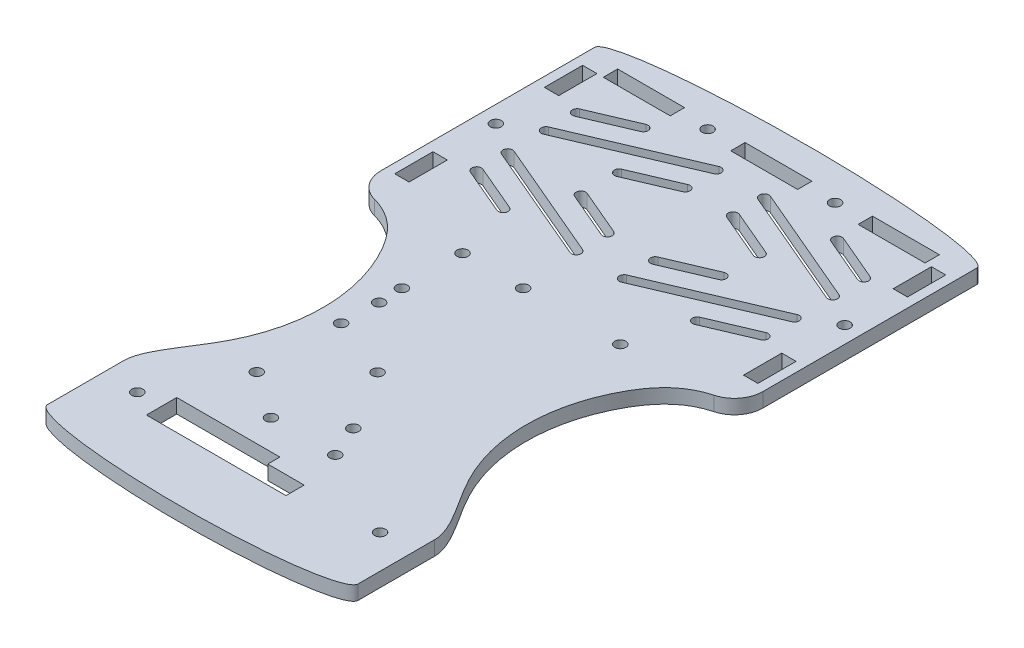
from build123d import *

# Parameters (mm, degrees)
SKETCH1_W           = 80
SKETCH1_H           = 100
BOSS_EXTRUDE1_DEPTH = 1.5
SKETCH2_R           = 1.15
SKETCH2_W           = 14
SKETCH2_H           = 3
CUT_EXTRUDE1_DEPTH  = 4
SKETCH3_R           = 1.15
SKETCH3_W           = 3
SKETCH3_H           = 8
CUT_EXTRUDE2_DEPTH  = 4
CUT_EXTRUDE3_DEPTH  = 4
BOSS_EXTRUDE2_DEPTH = 3
SKETCH9_W           = 80
SKETCH9_H           = 6
BOSS_EXTRUDE3_DEPTH = 3
CUT_EXTRUDE4_DEPTH  = 4.0000001
BOSS_EXTRUDE4_DEPTH = 3
SKETCH12_R          = 1.143
CUT_EXTRUDE5_DEPTH  = 4.0000001
SKETCH13_R          = 1.15
CUT_EXTRUDE6_DEPTH  = 4.0000001
CUT_EXTRUDE7_DEPTH  = 4.0000001
FILLET1_R           = 6
SKETCH16_R          = 1.15
CUT_EXTRUDE8_DEPTH  = 4.0000001


with BuildPart() as part:
    # Sketch1 → Boss-Extrude1 (new body, symmetric)
    with BuildSketch(Plane(origin=(0, 0, 0), x_dir=(1, 0, 0), z_dir=(0, 1, 0))):
        Rectangle(SKETCH1_W, SKETCH1_H)
    extrude(amount=BOSS_EXTRUDE1_DEPTH, both=True)

    # Sketch2 → Cut-Extrude1 (cut, through all)
    with BuildSketch(Plane(origin=(0, 1.5, 0), x_dir=(1, 0, 0), z_dir=(0, 1, 0))):
        with Locations((-13.333333333, 47)):
            Circle(SKETCH2_R)
        with Locations((13.333333333, 47)):
            Circle(SKETCH2_R)
        with Locations((-26.666666667, 47)):
            Rectangle(SKETCH2_W, SKETCH2_H)
        with Locations((0, 47)):
            Rectangle(SKETCH2_W, SKETCH2_H)
        with Locations((26.666666667, 47)):
            Rectangle(SKETCH2_W, SKETCH2_H)
    extrude(amount=-CUT_EXTRUDE1_DEPTH, mode=Mode.SUBTRACT)

    # Sketch3 → Cut-Extrude2 (cut, through all)
    with BuildSketch(Plane(origin=(0, 1.5, 0), x_dir=(1, 0, 0), z_dir=(0, 1, 0))):
        with Locations((36.5, 25.841809836)):
            Circle(SKETCH3_R)
        with Locations((-36.5, 25.841809836)):
            Circle(SKETCH3_R)
        with Locations((-36.5, 41.5)):
            Rectangle(SKETCH3_W, SKETCH3_H)
        with Locations((-36.5, 10.183619672)):
            Rectangle(SKETCH3_W, SKETCH3_H)
        with Locations((36.5, 10.183619672)):
            Rectangle(SKETCH3_W, SKETCH3_H)
        with Locations((36.5, 41.5)):
            Rectangle(SKETCH3_W, SKETCH3_H)
    extrude(amount=-CUT_EXTRUDE2_DEPTH, mode=Mode.SUBTRACT)

    # Sketch4 → Cut-Extrude3 (cut, through all)
    with BuildSketch(Plane(origin=(0, 1.5, 0), x_dir=(1, 0, 0), z_dir=(0, 1, 0))):
        with BuildLine():
            Line((29.607825194, 28.921919124), (4.607825194, 39.580109288))
            ThreePointArc((4.607825194, 39.580109288), (4.080109288, 40.892174806), (5.392174806, 41.419890712))
            Line((5.392174806, 41.419890712), (30.392174806, 30.761700548))
            ThreePointArc((30.392174806, 30.761700548), (30.919890712, 29.44963503), (29.607825194, 28.921919124))
        make_face()
        with BuildLine():
            Line((14.3085252, 28.921919124), (4.607825194, 33.057595339))
            ThreePointArc((4.607825194, 33.057595339), (4.080109288, 34.369660857), (5.392174806, 34.897376763))
            Line((5.392174806, 34.897376763), (15.092874811, 30.761700548))
            ThreePointArc((15.092874811, 30.761700548), (15.620590717, 29.44963503), (14.3085252, 28.921919124))
        make_face()
        with BuildLine():
            Line((20.6914748, 41.419890712), (30.392174806, 37.284214497))
            ThreePointArc((30.392174806, 37.284214497), (30.919890712, 35.972148979), (29.607825194, 35.444433073))
            Line((29.607825194, 35.444433073), (19.907125189, 39.580109288))
            ThreePointArc((19.907125189, 39.580109288), (19.379409283, 40.892174806), (20.6914748, 41.419890712))
        make_face()
        with BuildLine():
            Line((29.607825194, 22.761700548), (4.607825194, 12.103510384))
            ThreePointArc((4.607825194, 12.103510384), (4.080109288, 10.791444866), (5.392174806, 10.26372896))
            Line((5.392174806, 10.26372896), (30.392174806, 20.921919124))
            ThreePointArc((30.392174806, 20.921919124), (30.919890712, 22.233984641), (29.607825194, 22.761700548))
        make_face()
        with BuildLine():
            Line((14.3085252, 22.761700548), (4.607825194, 18.626024332))
            ThreePointArc((4.607825194, 18.626024332), (4.080109288, 17.313958815), (5.392174806, 16.786242909))
            Line((5.392174806, 16.786242909), (15.092874811, 20.921919124))
            ThreePointArc((15.092874811, 20.921919124), (15.620590717, 22.233984641), (14.3085252, 22.761700548))
        make_face()
        with BuildLine():
            Line((20.6914748, 10.26372896), (30.392174806, 14.399405175))
            ThreePointArc((30.392174806, 14.399405175), (30.919890712, 15.711470693), (29.607825194, 16.239186599))
            Line((29.607825194, 16.239186599), (19.907125189, 12.103510384))
            ThreePointArc((19.907125189, 12.103510384), (19.379409283, 10.791444866), (20.6914748, 10.26372896))
        make_face()
        with BuildLine():
            Line((-29.607825194, 28.921919124), (-4.607825194, 39.580109288))
            ThreePointArc((-4.607825194, 39.580109288), (-4.080109288, 40.892174806), (-5.392174806, 41.419890712))
            Line((-5.392174806, 41.419890712), (-30.392174806, 30.761700548))
            ThreePointArc((-30.392174806, 30.761700548), (-30.919890712, 29.44963503), (-29.607825194, 28.921919124))
        make_face()
        with BuildLine():
            Line((-14.3085252, 28.921919124), (-4.607825194, 33.057595339))
            ThreePointArc((-4.607825194, 33.057595339), (-4.080109288, 34.369660857), (-5.392174806, 34.897376763))
            Line((-5.392174806, 34.897376763), (-15.092874811, 30.761700548))
            ThreePointArc((-15.092874811, 30.761700548), (-15.620590717, 29.44963503), (-14.3085252, 28.921919124))
        make_face()
        with BuildLine():
            Line((-20.6914748, 41.419890712), (-30.392174806, 37.284214497))
            ThreePointArc((-30.392174806, 37.284214497), (-30.919890712, 35.972148979), (-29.607825194, 35.444433073))
            Line((-29.607825194, 35.444433073), (-19.907125189, 39.580109288))
            ThreePointArc((-19.907125189, 39.580109288), (-19.379409283, 40.892174806), (-20.6914748, 41.419890712))
        make_face()
        with BuildLine():
            Line((-29.607825194, 22.761700548), (-4.607825194, 12.103510384))
            ThreePointArc((-4.607825194, 12.103510384), (-4.080109288, 10.791444866), (-5.392174806, 10.26372896))
            Line((-5.392174806, 10.26372896), (-30.392174806, 20.921919124))
            ThreePointArc((-30.392174806, 20.921919124), (-30.919890712, 22.233984641), (-29.607825194, 22.761700548))
        make_face()
        with BuildLine():
            Line((-14.3085252, 22.761700548), (-4.607825194, 18.626024332))
            ThreePointArc((-4.607825194, 18.626024332), (-4.080109288, 17.313958815), (-5.392174806, 16.786242909))
            Line((-5.392174806, 16.786242909), (-15.092874811, 20.921919124))
            ThreePointArc((-15.092874811, 20.921919124), (-15.620590717, 22.233984641), (-14.3085252, 22.761700548))
        make_face()
        with BuildLine():
            Line((-20.6914748, 10.26372896), (-30.392174806, 14.399405175))
            ThreePointArc((-30.392174806, 14.399405175), (-30.919890712, 15.711470693), (-29.607825194, 16.239186599))
            Line((-29.607825194, 16.239186599), (-19.907125189, 12.103510384))
            ThreePointArc((-19.907125189, 12.103510384), (-19.379409283, 10.791444866), (-20.6914748, 10.26372896))
        make_face()
    extrude(amount=-CUT_EXTRUDE3_DEPTH, mode=Mode.SUBTRACT)

    # Sketch5 → Boss-Extrude2 (add)
    with BuildSketch(Plane(origin=(0, 1.5, 0), x_dir=(1, 0, 0), z_dir=(0, 1, 0))):
        with BuildLine():
            Line((40, 50), (-40, 50))
            add(Edge.make_bspline(
                [(40, 50), (40, 54.5), (0, 54.5), (-40, 54.5), (-40, 50)],
                knots=[3.141592654, 3.141592654, 3.141592654, 4.71238898, 4.71238898, 6.283185307, 6.283185307, 6.283185307], degree=2, weights=[1, 0.707106781, 1, 0.707106781, 1]))
        make_face()
    extrude(amount=-BOSS_EXTRUDE2_DEPTH)

    # Sketch9 → Boss-Extrude3 (add)
    with BuildSketch(Plane(origin=(0, 1.5, 0), x_dir=(1, 0, 0), z_dir=(0, 1, 0))):
        with Locations((0, -53)):
            Rectangle(SKETCH9_W, SKETCH9_H)
    extrude(amount=-BOSS_EXTRUDE3_DEPTH)

    # Sketch7 → Cut-Extrude4 (cut, through all)
    with BuildSketch(Plane(origin=(0, 1.5, 0), x_dir=(1, 0, 0), z_dir=(0, 1, 0))):
        with BuildLine():
            Line((40, 0), (40, -56))
            Line((40, -56), (32.5, -56))
            add(Edge.make_bspline(
                [(40, 0), (32.098052341, 0), (20.551318803, -12.467121646), (19.339671373, -36.932831807), (32.5, -51.97801632), (32.5, -56)],
                knots=[0, 0, 0, 0, 0.268690214, 0.752947844, 1, 1, 1, 1], degree=3))
        make_face()
        with BuildLine():
            Line((-40, -56), (-32.5, -56))
            add(Edge.make_bspline(
                [(-40, 0), (-32.098052341, 0), (-20.551318803, -12.467121646), (-19.339671373, -36.932831807), (-32.5, -51.97801632), (-32.5, -56)],
                knots=[0, 0, 0, 0, 0.268690214, 0.752947844, 1, 1, 1, 1], degree=3))
            Line((-40, 0), (-40, -56))
        make_face()
    extrude(amount=-CUT_EXTRUDE4_DEPTH, mode=Mode.SUBTRACT)

    # Sketch11 → Boss-Extrude4 (add)
    with BuildSketch(Plane.XZ.offset(1.5)):
        with BuildLine():
            Line((32.5, 56), (32.5, 72))
            add(Edge.make_bspline(
                [(32.5, 72), (32.5, 76.5), (0, 76.5), (-32.5, 76.5), (-32.5, 72)],
                knots=[0, 0, 0, 1.570796327, 1.570796327, 3.141592654, 3.141592654, 3.141592654], degree=2, weights=[1, 0.707106781, 1, 0.707106781, 1]))
            Line((-32.5, 72), (-32.5, 56))
            Line((-32.5, 56), (32.5, 56))
        make_face()
    extrude(amount=-BOSS_EXTRUDE4_DEPTH)

    # Sketch12 → Cut-Extrude5 (cut, through all)
    with BuildSketch(Plane(origin=(0, 1.5, 0), x_dir=(1, 0, 0), z_dir=(0, 1, 0))):
        with Locations((-6.731, -51)):
            Circle(SKETCH12_R)
        with Locations((6.731, -51)):
            Circle(SKETCH12_R)
    extrude(amount=-CUT_EXTRUDE5_DEPTH, mode=Mode.SUBTRACT)

    # Sketch13 → Cut-Extrude6 (cut, through all)
    with BuildSketch(Plane(origin=(0, 1.5, 0), x_dir=(1, 0, 0), z_dir=(0, 1, 0))):
        with Locations((25.46, -60.356380328)):
            Circle(SKETCH13_R)
        with Locations((-25.34, -60.356380328)):
            Circle(SKETCH13_R)
    extrude(amount=-CUT_EXTRUDE6_DEPTH, mode=Mode.SUBTRACT)

    # Sketch15 → Cut-Extrude7 (cut, through all)
    with BuildSketch(Plane.XZ.offset(1.5)):
        Polygon((1.33, 57.181380328), (-20.26, 57.181380328), (-20.26, 63.531380328), (8.95, 63.531380328), (8.95, 59.721380328), (1.33, 59.721380328), align=None)
    extrude(amount=-CUT_EXTRUDE7_DEPTH, mode=Mode.SUBTRACT)

    # Fillet1
    fillet1_edges = [part.edges().sort_by_distance(p)[0] for p in [
        (40, 0, 0),
        (-40, 0, 0),
    ]]
    fillet(fillet1_edges, radius=FILLET1_R)

    # Sketch16 → Cut-Extrude8 (cut, through all)
    with BuildSketch(Plane.XZ.offset(1.5)):
        with Locations((-16.51, 13.826380328)):
            Circle(SKETCH16_R)
        with Locations((-16.296758127, 18.795764095)):
            Circle(SKETCH16_R)
        with Locations((-16.51, 26.526380328)):
            Circle(SKETCH16_R)
        with Locations((3.81, 44.306380328)):
            Circle(SKETCH16_R)
        with Locations((-3.81, 1.126380328)):
            Circle(SKETCH16_R)
        with Locations((16.51, 1.126380328)):
            Circle(SKETCH16_R)
        with Locations((-16.51, 1.126380328)):
            Circle(SKETCH16_R)
        with Locations((-3.81, 31.606380328)):
            Circle(SKETCH16_R)
        with Locations((-16.499422109, 44.194955565)):
            Circle(SKETCH16_R)
    extrude(amount=-CUT_EXTRUDE8_DEPTH, mode=Mode.SUBTRACT)


solid = part.part
